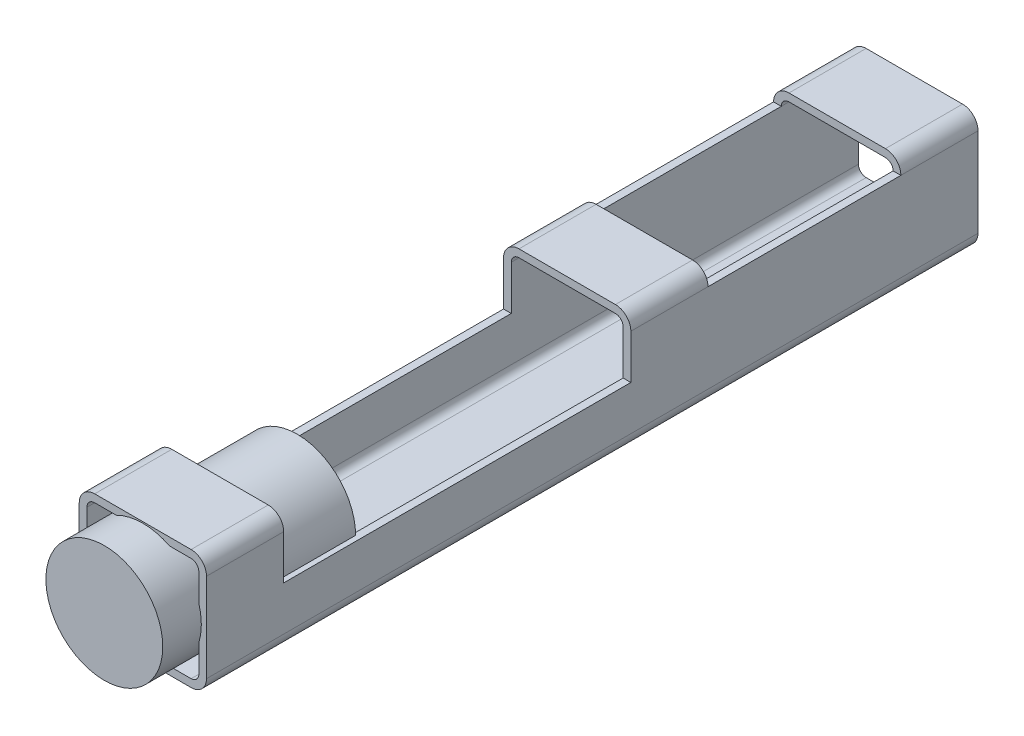
from build123d import *

# Parameters (mm, degrees)
BODY_DEPTH         = 10
SKETCH2_W          = 2.5
SKETCH2_H          = 0.2
SKETCH2_W_2        = 4.5
SKETCH2_H_2        = 0.775
CUT_EXTRUDE1_DEPTH = 1.65
SKETCH3_R          = 0.757347034
WIRE_2_DEPTH       = 0.5
WIRE_2_DEPTH_BACK  = 2


with BuildPart() as part:
    # Sketch1 → Body (new body)
    with BuildSketch(Plane.XY):
        with BuildLine():
            Line((0.625, -0.775), (-0.625, -0.775))
            ThreePointArc((-0.625, -0.775), (-0.766421356, -0.716421356), (-0.825, -0.575))
            Line((-0.825, -0.575), (-0.825, 0.575))
            ThreePointArc((-0.825, 0.575), (-0.766421356, 0.716421356), (-0.625, 0.775))
            Line((-0.625, 0.775), (0.625, 0.775))
            ThreePointArc((0.625, 0.775), (0.766421356, 0.716421356), (0.825, 0.575))
            Line((0.825, 0.575), (0.825, -0.575))
            ThreePointArc((0.825, -0.575), (0.766421356, -0.716421356), (0.625, -0.775))
        make_face()
        with BuildLine():
            Line((-0.725, -0.575), (-0.725, 0.575))
            ThreePointArc((-0.725, 0.575), (-0.695710678, 0.645710678), (-0.625, 0.675))
            Line((-0.625, 0.675), (0.625, 0.675))
            ThreePointArc((0.625, 0.675), (0.695710678, 0.645710678), (0.725, 0.575))
            Line((0.725, 0.575), (0.725, -0.575))
            ThreePointArc((0.725, -0.575), (0.695710678, -0.645710678), (0.625, -0.675))
            Line((0.625, -0.675), (-0.625, -0.675))
            ThreePointArc((-0.625, -0.675), (-0.695710678, -0.645710678), (-0.725, -0.575))
        make_face(mode=Mode.SUBTRACT)
    extrude(amount=BODY_DEPTH)

    # Sketch2 → Cut-Extrude1 (cut)
    with BuildSketch(Plane.ZY.offset(0.825)):
        with Locations((2.25, 0.675)):
            Rectangle(SKETCH2_W, SKETCH2_H)
        with Locations((6.75, 0.3875)):
            Rectangle(SKETCH2_W_2, SKETCH2_H_2)
    extrude(amount=-CUT_EXTRUDE1_DEPTH, mode=Mode.SUBTRACT)

    # Sketch3 → Wire 2 (add, two sides)
    with BuildSketch(Plane.XY.offset(10)) as wire_2_sk:
        Circle(SKETCH3_R)
    extrude(amount=WIRE_2_DEPTH)
    extrude(wire_2_sk.sketch, amount=-WIRE_2_DEPTH_BACK)


solid = part.part
